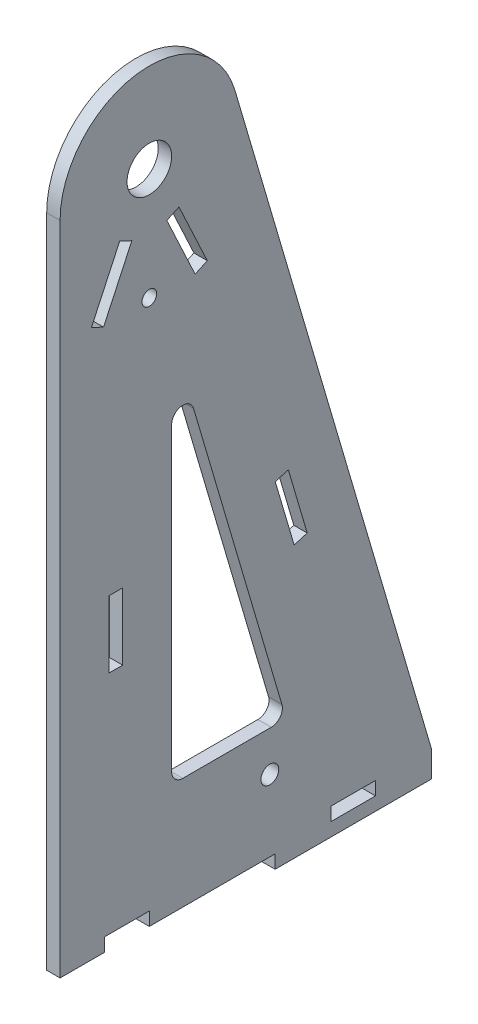
from build123d import *

# Parameters (mm, degrees)
SKETCH1_R               = 5
SKETCH1_R_2             = 1.65
BOSS_EXTRUDE1_DEPTH     = 3
FILLET1_R               = 2.5
CUT_EXTRUDE1_DEPTH      = 161.031050379
CUT_EXTRUDE1_DEPTH_BACK = 161.031050379
SKETCH2_W               = 10
SKETCH2_H               = 3
BOSS_EXTRUDE2_DEPTH     = 3
CUT_EXTRUDE2_DEPTH      = 163.79108417
CUT_EXTRUDE2_DEPTH_BACK = 163.79108417
SKETCH4_R               = 2
SKETCH4_W               = 3.05
SKETCH4_H               = 15


with BuildPart() as part:
    # Sketch1 → Boss-Extrude1 (new body)
    with BuildSketch(Plane(origin=(0, 0, 0), x_dir=(0, 0, -1), z_dir=(1, 0, 0))):
        with BuildLine():
            Line((-20, -147), (-20, 0))
            ThreePointArc((-20, 0), (-2.849659193, 19.795945102), (19.187944249, 5.641169694))
            Line((19.187944249, 5.641169694), (63.181778112, -144))
            Line((63.181778112, -144), (63.181778112, -147))
            Line((63.181778112, -147), (-20, -147))
        make_face()
        Circle(SKETCH1_R, mode=Mode.SUBTRACT)
        with Locations((0, -25)):
            Circle(SKETCH1_R_2, mode=Mode.SUBTRACT)
        Polygon((5, -34.733881779), (5, -122), (30.655848018, -122), align=None, mode=Mode.SUBTRACT)
        Polygon((10.262540517, -25.557391536), (3.923266591, -11.962774731), (6.642189952, -10.694919945), (12.981463878, -24.289536751), align=None, mode=Mode.SUBTRACT)
        Polygon((-12.981463878, -24.289536751), (-6.642189952, -10.694919945), (-3.923266591, -11.962774731), (-10.262540517, -25.557391536), align=None, mode=Mode.SUBTRACT)
    extrude(amount=BOSS_EXTRUDE1_DEPTH)

    # Fillet1
    fillet1_edges = [part.edges().sort_by_distance(p)[0] for p in [
        (1.5, -34.733881779, -5),
        (1.5, -122, -30.655848018),
        (1.5, -122, -5),
    ]]
    fillet(fillet1_edges, radius=FILLET1_R)

    # Sketch2 → Cut-Extrude1 (cut, two sides: drawn at the far end of the back side and taken through both)
    with BuildSketch(Plane(origin=(3, 0, 0), x_dir=(0, 0, -1), z_dir=(1, 0, 0)).offset(-CUT_EXTRUDE1_DEPTH_BACK)):
        with Locations((-5, -145.5)):
            Rectangle(SKETCH2_W, SKETCH2_H)
        with Locations((45.681778112, -145.5)):
            Rectangle(SKETCH2_W, SKETCH2_H)
    extrude(amount=CUT_EXTRUDE1_DEPTH + CUT_EXTRUDE1_DEPTH_BACK, mode=Mode.SUBTRACT)

    # Sketch2_3 → Boss-Extrude2 (add)
    with BuildSketch(Plane(origin=(3, 0, 0), x_dir=(0, 0, -1), z_dir=(1, 0, 0))):
        Polygon((50.681778112, -147), (40.681778112, -147), (28.181778112, -147), (28.181778112, -150), (63.181778112, -150), (63.181778112, -147), align=None)
    extrude(amount=-BOSS_EXTRUDE2_DEPTH)

    # Sketch4 → Cut-Extrude2 (cut, two sides: drawn at the far end of the back side and taken through both)
    with BuildSketch(Plane(origin=(3, 0, 0), x_dir=(0, 0, -1), z_dir=(1, 0, 0)).offset(-CUT_EXTRUDE2_DEPTH_BACK)):
        with Locations((27, -131)):
            Circle(SKETCH4_R)
        Polygon((32.450844249, -89.195152346), (28.219966978, -74.804194159), (31.146128476, -73.943915781), (35.377005747, -88.334873967), align=None)
        with Locations((-7.5, -85.800411334)):
            Rectangle(SKETCH4_W, SKETCH4_H)
    extrude(amount=CUT_EXTRUDE2_DEPTH + CUT_EXTRUDE2_DEPTH_BACK, mode=Mode.SUBTRACT)


solid = part.part
